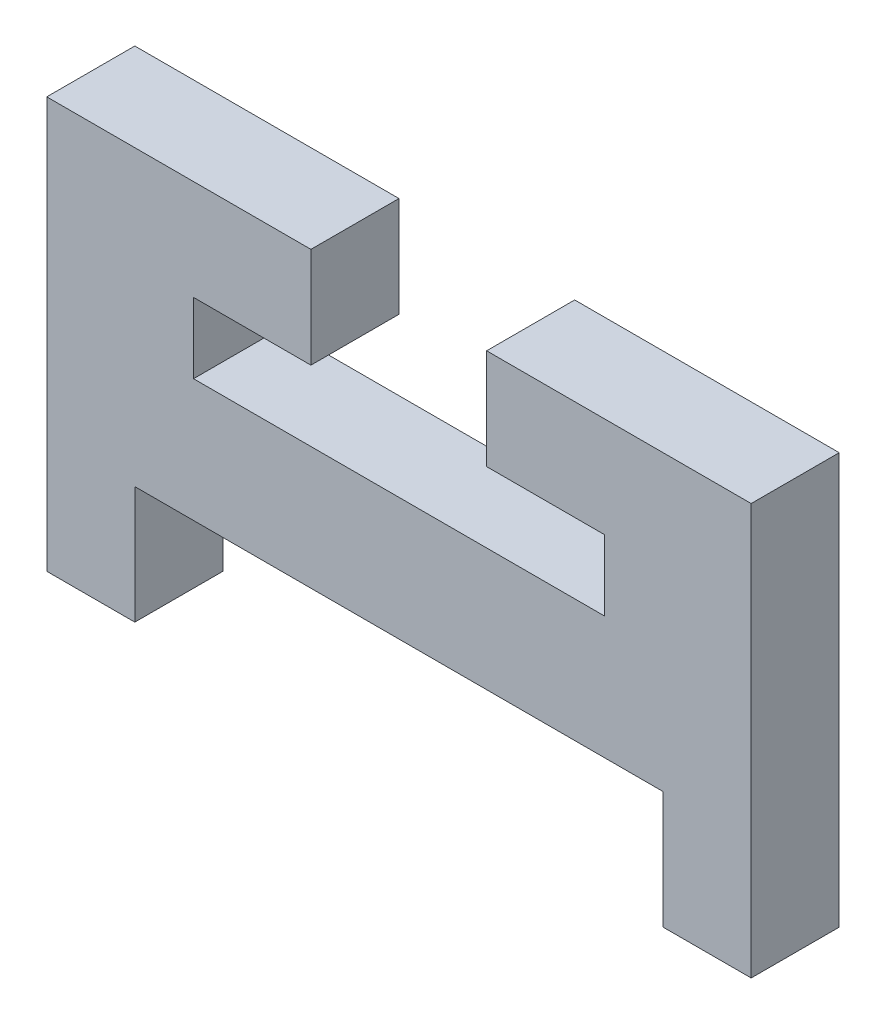
from build123d import *

# Parameters (mm, degrees)
SALIENTE_EXTRUIR1_DEPTH = 3


with BuildPart() as part:
    # Model → Saliente-Extruir1 (new body)
    with BuildSketch(Plane.XY):
        Polygon((33.6, 16.082683294), (26.1, 16.082683294), (26.1, 18.482683294), (30.1, 18.482683294), (30.1, 21.9), (21.1, 21.9), (21.1, 7.9), (24.1, 7.9), (24.1, 11.9), (42.1, 11.9), (42.1, 7.9), (45.1, 7.9), (45.1, 21.9), (36.086385402, 21.9), (36.086385402, 18.482683294), (40.1, 18.482683294), (40.1, 16.082683294), align=None)
    extrude(amount=SALIENTE_EXTRUIR1_DEPTH)


solid = part.part
